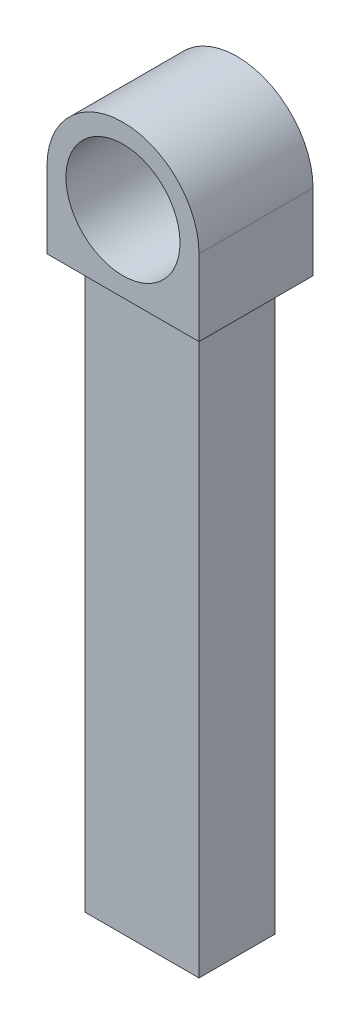
from build123d import *

# Parameters (mm, degrees)
SKETCH_1_R      = 2
SKETCH_1_R_2    = 1.5
EXTRUDE_1_DEPTH = 3
SKETCH_2_W      = 3
SKETCH_2_H      = 2
EXTRUDE_2_DEPTH = 15


with BuildPart() as part:
    # 草图1 → 凸台-拉伸1 (new body)
    with BuildSketch(Plane.XY):
        with BuildLine():
            ThreePointArc((0, -2), (-1.414213562, -1.414213562), (-2, 0))
            Line((-2, 0), (-2, -2))
            Line((-2, -2), (0, -2))
        make_face()
        Circle(SKETCH_1_R)
        Circle(SKETCH_1_R_2, mode=Mode.SUBTRACT)
        with BuildLine():
            Line((2, -2), (2, 0))
            ThreePointArc((2, 0), (1.414213562, -1.414213562), (0, -2))
            Line((0, -2), (2, -2))
        make_face()
    extrude(amount=EXTRUDE_1_DEPTH)

    # 草图2 → 凸台-拉伸2 (add)
    with BuildSketch(Plane.XZ.offset(2)):
        with Locations((0, 1.5)):
            Rectangle(SKETCH_2_W, SKETCH_2_H)
    extrude(amount=EXTRUDE_2_DEPTH)


solid = part.part
